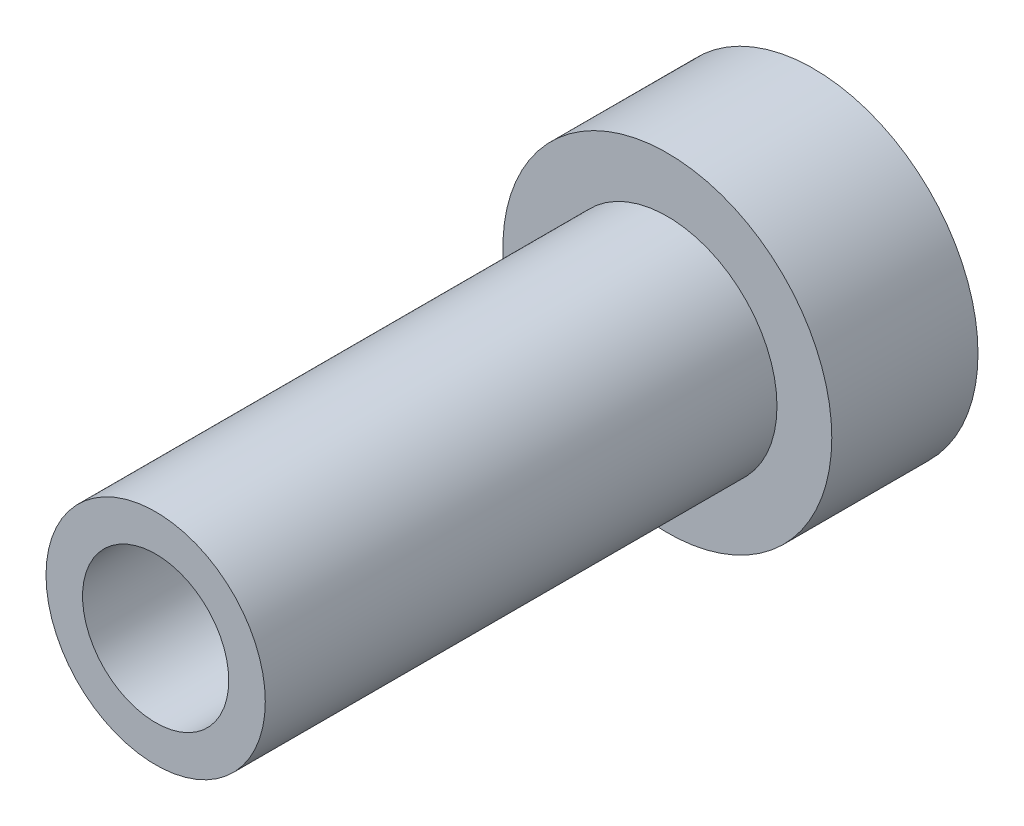
from build123d import *

# Parameters (mm, degrees)
IZIM1_R                     = 2.25
Y_KSEKLIK_EKSTR_ZYON1_DEPTH = 2
IZIM2_R                     = 1.5
IZIM2_R_2                   = 1
Y_KSEKLIK_EKSTR_ZYON2_DEPTH = 7


with BuildPart() as part:
    # Çizim1 → Yükseklik-Ekstrüzyon1 (new body)
    with BuildSketch(Plane.XY):
        Circle(IZIM1_R)
    extrude(amount=Y_KSEKLIK_EKSTR_ZYON1_DEPTH)

    # Çizim2 → Yükseklik-Ekstrüzyon2 (add)
    with BuildSketch(Plane.XY.offset(2)):
        Circle(IZIM2_R)
        Circle(IZIM2_R_2, mode=Mode.SUBTRACT)
    extrude(amount=Y_KSEKLIK_EKSTR_ZYON2_DEPTH)


solid = part.part
